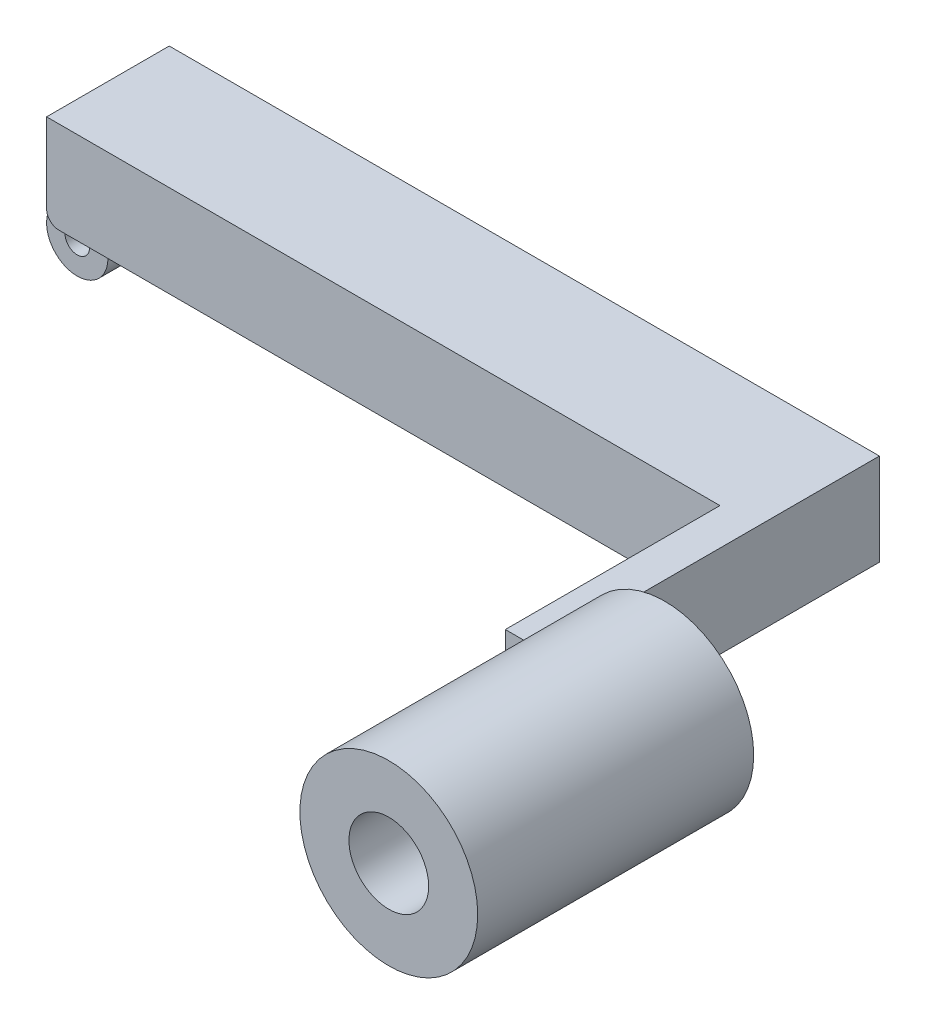
from build123d import *

# Parameters (mm, degrees)
SKETCH4_W                = 20
SKETCH4_H                = 15
BOSS_EXTRUDE1_DEPTH      = 115.8
SKETCH5_W                = 6
SKETCH5_H                = 15
BOSS_EXTRUDE2_DEPTH      = 35
SKETCH6_R                = 14.5
SKETCH6_R_2              = 6.5
BOSS_EXTRUDE3_DEPTH      = 35
BOSS_EXTRUDE3_DEPTH_BACK = 10
SKETCH7_R                = 2
BOSS_EXTRUDE4_DEPTH      = 5
FILLET1_R                = 2


with BuildPart() as part:
    # Sketch4 → Boss-Extrude1 (new body)
    with BuildSketch(Plane(origin=(0, 0, 0), x_dir=(0, 0, -1), z_dir=(1, 0, 0))):
        Rectangle(SKETCH4_W, SKETCH4_H)
    extrude(amount=BOSS_EXTRUDE1_DEPTH)

    # Sketch5 → Boss-Extrude2 (add)
    with BuildSketch(Plane.XY.offset(10)):
        with Locations((112.8, 0)):
            Rectangle(SKETCH5_W, SKETCH5_H)
    extrude(amount=BOSS_EXTRUDE2_DEPTH)

    # Sketch6 → Boss-Extrude3 (add, two sides)
    with BuildSketch(Plane.XY.offset(45)) as boss_extrude3_sk:
        with Locations((125.8, 0)):
            Circle(SKETCH6_R)
        with Locations((125.8, 0)):
            Circle(SKETCH6_R_2, mode=Mode.SUBTRACT)
    extrude(amount=BOSS_EXTRUDE3_DEPTH)
    extrude(boss_extrude3_sk.sketch, amount=-BOSS_EXTRUDE3_DEPTH_BACK)

    # Sketch7 → Boss-Extrude4 (add, symmetric)
    with BuildSketch(Plane.XY):
        with BuildLine():
            Line((5, -12.5), (5, -7.5))
            Line((5, -7.5), (0, -7.5))
            ThreePointArc((0, -7.5), (-3.535533906, -16.035533906), (5, -12.5))
        make_face()
        with Locations((0, -12.5)):
            Circle(SKETCH7_R, mode=Mode.SUBTRACT)
    extrude(amount=BOSS_EXTRUDE4_DEPTH, both=True)

    # Fillet1
    fillet1_edges = [part.edges().sort_by_distance(p)[0] for p in [
        (0, -7.5, -7.5),
        (0, -7.5, 7.5),
    ]]
    fillet(fillet1_edges, radius=FILLET1_R)


solid = part.part
